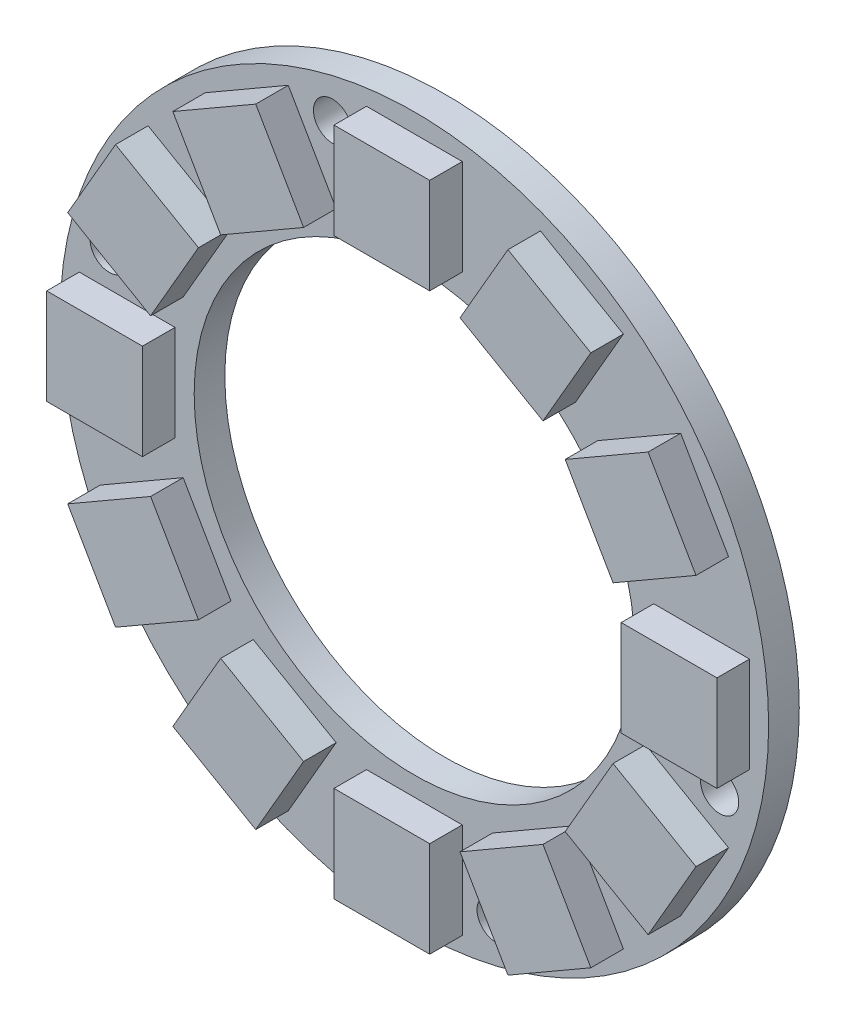
from build123d import *

# Parameters (mm, degrees)
SKETCH1_R           = 18.5
SKETCH1_R_2         = 11.5
BOSS_EXTRUDE1_DEPTH = 1.6
SKETCH2_W           = 5
SKETCH2_H           = 5
BOSS_EXTRUDE2_DEPTH = 1.7
CIRPATTERN1_COUNT   = 12
SKETCH3_R           = 1
CUT_EXTRUDE1_DEPTH  = 2
CIRPATTERN2_COUNT   = 2
SKETCH4_R           = 1
CUT_EXTRUDE2_DEPTH  = 10
CIRPATTERN3_COUNT   = 2


with BuildPart() as part:
    # Sketch1 → Boss-Extrude1 (new body)
    with BuildSketch(Plane.XY):
        Circle(SKETCH1_R)
        Circle(SKETCH1_R_2, mode=Mode.SUBTRACT)
    extrude(amount=BOSS_EXTRUDE1_DEPTH)

    # Sketch2 → Boss-Extrude2 (add)
    with BuildSketch(Plane.XY.offset(1.6)):
        with Locations((0, 15)):
            Rectangle(SKETCH2_W, SKETCH2_H)
    boss_extrude2 = extrude(amount=BOSS_EXTRUDE2_DEPTH)

    # CirPattern1: Boss-Extrude2 ×12 about axis
    cirpattern1_axis = Axis((0, 0, 1.6), (0, 0, -1))
    for i in range(1, CIRPATTERN1_COUNT):
        add(boss_extrude2.rotate(cirpattern1_axis, i * 360 / CIRPATTERN1_COUNT))

    # Sketch3 → Cut-Extrude1 (cut)
    with BuildSketch(Plane.XY.offset(1.6)):
        with Locations((-4.270514244, 15.937776134)):
            Circle(SKETCH3_R)
    cut_extrude1 = extrude(amount=-CUT_EXTRUDE1_DEPTH, mode=Mode.SUBTRACT)

    # CirPattern2: Cut-Extrude1 ×2 about axis
    cirpattern2_axis = Axis((0, 0, 1.6), (0, 0, -1))
    for i in range(1, CIRPATTERN2_COUNT):
        add(cut_extrude1.rotate(cirpattern2_axis, i * 360 / CIRPATTERN2_COUNT), mode=Mode.SUBTRACT)

    # Sketch4 → Cut-Extrude2 (cut)
    with BuildSketch(Plane.XY.offset(1.6)):
        with Locations((-15.937776134, 4.270514244)):
            Circle(SKETCH4_R)
    cut_extrude2 = extrude(amount=-CUT_EXTRUDE2_DEPTH, mode=Mode.SUBTRACT)

    # CirPattern3: Cut-Extrude2 ×2 about axis
    cirpattern3_axis = Axis((0, 0, 1.6), (0, 0, -1))
    for i in range(1, CIRPATTERN3_COUNT):
        add(cut_extrude2.rotate(cirpattern3_axis, i * 360 / CIRPATTERN3_COUNT), mode=Mode.SUBTRACT)


solid = part.part
